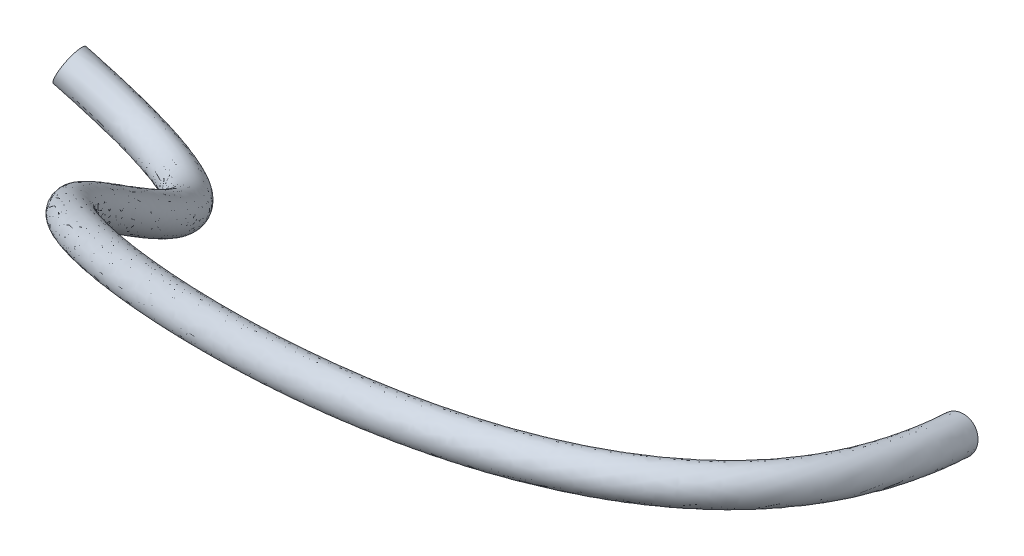
from build123d import *

# Parameters (mm, degrees)
SWEEP_1_PROFILE_R = 3


with BuildPart() as part:
    # 扫描1: sweep along a curve in space
    with BuildLine() as sweep_1_path:
        add(Edge.make_bspline(
            [(0, 0, 0), (14.129846113, 17.814985291, 76.522227111), (-174.331561905, -6.387742285, 39.780807808), (-176.481098456, -99.443941221, -67.026480023), (-213.591266831, -82.601851994, -61.411339843)],
            knots=[0, 0, 0, 0, 0.644857457, 1, 1, 1, 1], degree=3))
    # 扫描1 profile (on start of the path) → 扫描1 (sweep)
    with BuildSketch(Plane(origin=(0, 0, 0), x_dir=(0, 0.973954314, -0.226744339), z_dir=(0.177001302, 0.223164185, 0.958576176))):
        Circle(SWEEP_1_PROFILE_R)
    sweep(path=sweep_1_path.line)


solid = part.part
